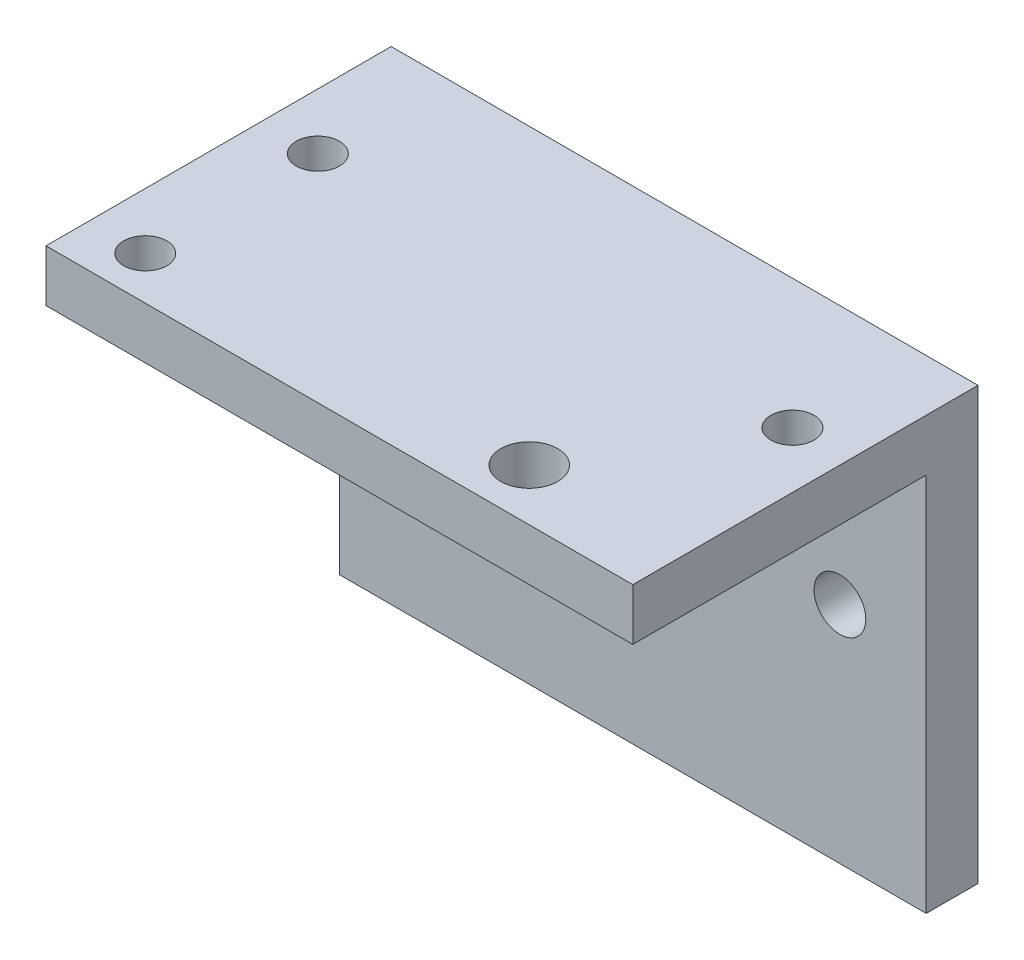
from build123d import *

# Parameters (mm, degrees)
SKETCH_1_W          = 68
SKETCH_1_H          = 40
SKETCH_1_R          = 2.5
EXTRUDE_1_DEPTH     = 6
SKETCH_3_W          = 68
SKETCH_3_H          = 6
EXTRUDE_2_DEPTH     = 50
CUT_EXTRUDE_1_REACH = 8
SKETCH_4_R          = 8
SKETCH_4_R_2        = 3
SKETCH_5_R          = 3.3
CUT_EXTRUDE_2_DEPTH = 10


with BuildPart() as part:
    # 草图1 → 凸台-拉伸1 (new body)
    with BuildSketch(Plane(origin=(0, 0, 0), x_dir=(1, 0, 0), z_dir=(0, 1, 0))):
        with Locations((0, 20)):
            Rectangle(SKETCH_1_W, SKETCH_1_H)
        with Locations((-27.5, 25)):
            Circle(SKETCH_1_R, mode=Mode.SUBTRACT)
        with Locations((27.5, 25)):
            Circle(SKETCH_1_R, mode=Mode.SUBTRACT)
        with Locations((-27.5, 5)):
            Circle(SKETCH_1_R, mode=Mode.SUBTRACT)
    extrude(amount=EXTRUDE_1_DEPTH)

    # 草图3 → 凸台-拉伸2 (add)
    with BuildSketch(Plane(origin=(0, 6, 0), x_dir=(1, 0, 0), z_dir=(0, 1, 0))):
        with Locations((0, 37)):
            Rectangle(SKETCH_3_W, SKETCH_3_H)
    extrude(amount=-EXTRUDE_2_DEPTH)

    # 草图4 → 切除-拉伸1 (cut, up to next)
    with BuildSketch(Plane.XY.offset(-34), mode=Mode.PRIVATE) as cut_extrude_1_sk1:
        with Locations((0, -18)):
            Circle(SKETCH_4_R)
    cut_extrude_1_tool1 = extrude(cut_extrude_1_sk1.sketch, amount=-CUT_EXTRUDE_1_REACH, mode=Mode.PRIVATE) & part.part
    add(cut_extrude_1_tool1.solids().sort_by_distance((0, -18, -34))[0], mode=Mode.SUBTRACT)
    # 草图4 → 切除-拉伸1 (cut, up to next)
    with BuildSketch(Plane.XY.offset(-34), mode=Mode.PRIVATE) as cut_extrude_1_sk2:
        with Locations((24, -18)):
            Circle(SKETCH_4_R_2)
    cut_extrude_1_tool2 = extrude(cut_extrude_1_sk2.sketch, amount=-CUT_EXTRUDE_1_REACH, mode=Mode.PRIVATE) & part.part
    add(cut_extrude_1_tool2.solids().sort_by_distance((24, -18, -34))[0], mode=Mode.SUBTRACT)
    # 草图4 → 切除-拉伸1 (cut, up to next)
    with BuildSketch(Plane.XY.offset(-34), mode=Mode.PRIVATE) as cut_extrude_1_sk3:
        with Locations((-24, -18)):
            Circle(SKETCH_4_R_2)
    cut_extrude_1_tool3 = extrude(cut_extrude_1_sk3.sketch, amount=-CUT_EXTRUDE_1_REACH, mode=Mode.PRIVATE) & part.part
    add(cut_extrude_1_tool3.solids().sort_by_distance((-24, -18, -34))[0], mode=Mode.SUBTRACT)

    # 草图5 → 切除-拉伸2 (cut)
    with BuildSketch(Plane.XZ):
        with Locations((15.999999998, -6)):
            Circle(SKETCH_5_R)
    extrude(amount=-CUT_EXTRUDE_2_DEPTH, mode=Mode.SUBTRACT)


solid = part.part
